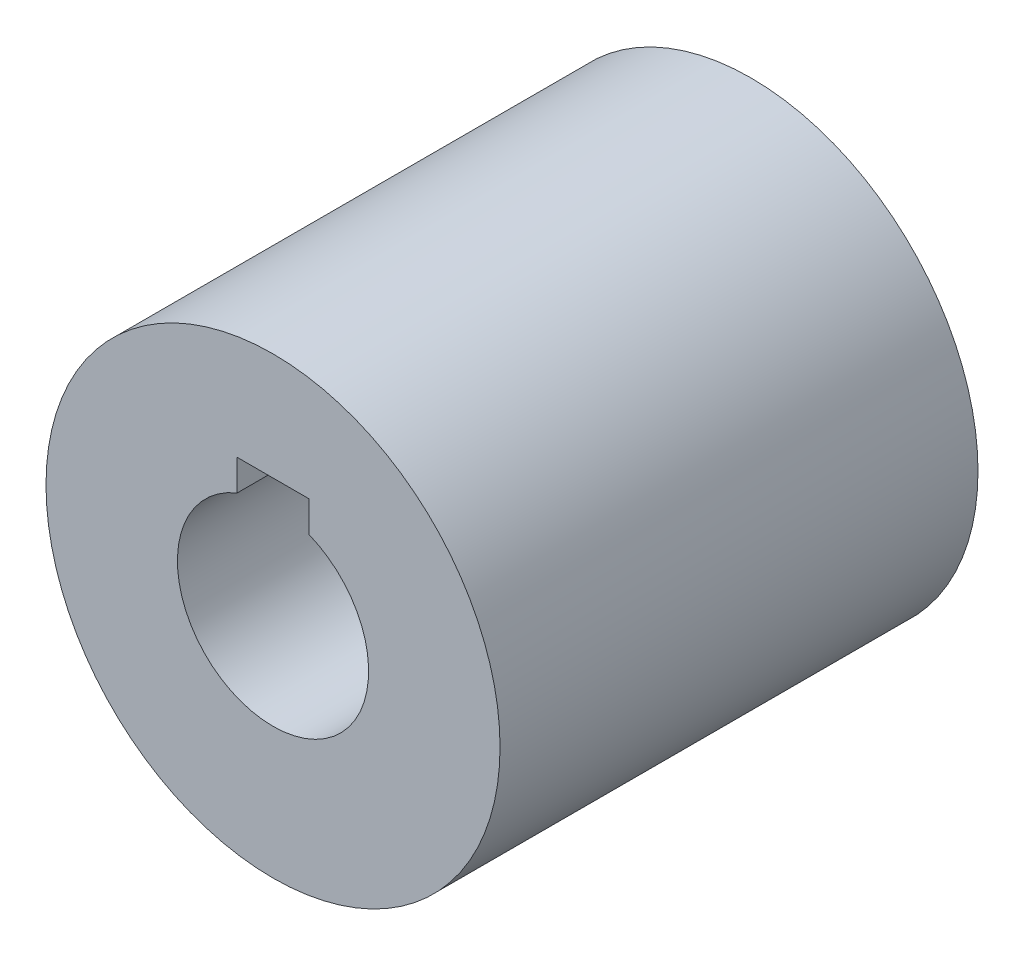
from build123d import *

# Parameters (mm, degrees)
SKETCH1_R           = 9.5
BOSS_EXTRUDE1_DEPTH = 20


with BuildPart() as part:
    # Sketch1 → Boss-Extrude1 (new body)
    with BuildSketch(Plane.XY):
        Circle(SKETCH1_R)
        with BuildLine():
            Line((-1.5, 3.708099244), (-1.5, 5))
            Line((-1.5, 5), (1.5, 5))
            Line((1.5, 5), (1.5, 3.708099244))
            ThreePointArc((1.5, 3.708099244), (0, -4), (-1.5, 3.708099244))
        make_face(mode=Mode.SUBTRACT)
    extrude(amount=BOSS_EXTRUDE1_DEPTH)


solid = part.part
